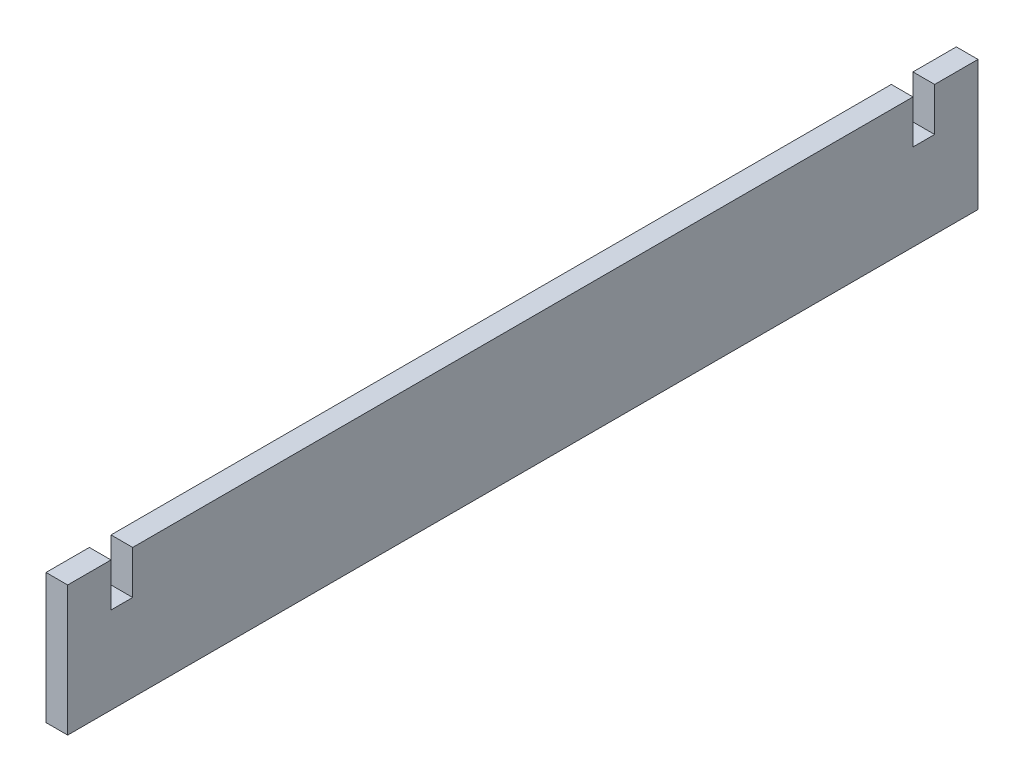
from build123d import *

# Parameters (mm, degrees)
SKETCH1_W           = 12.7
SKETCH1_H           = 76.2
BOSS_EXTRUDE1_DEPTH = 533.4
SKETCH2_W           = 12.7
SKETCH2_H           = 25.4
CUT_EXTRUDE1_DEPTH  = 13.7


with BuildPart() as part:
    # Sketch1 → Boss-Extrude1 (new body)
    with BuildSketch(Plane.XY):
        Rectangle(SKETCH1_W, SKETCH1_H)
    extrude(amount=BOSS_EXTRUDE1_DEPTH)

    # Sketch2 → Cut-Extrude1 (cut, through all)
    with BuildSketch(Plane(origin=(6.35, 0, 0), x_dir=(0, 0, -1), z_dir=(1, 0, 0))):
        with Locations((-501.65, 25.4)):
            Rectangle(SKETCH2_W, SKETCH2_H)
        with Locations((-31.75, 25.4)):
            Rectangle(SKETCH2_W, SKETCH2_H)
    extrude(amount=-CUT_EXTRUDE1_DEPTH, mode=Mode.SUBTRACT)


solid = part.part
